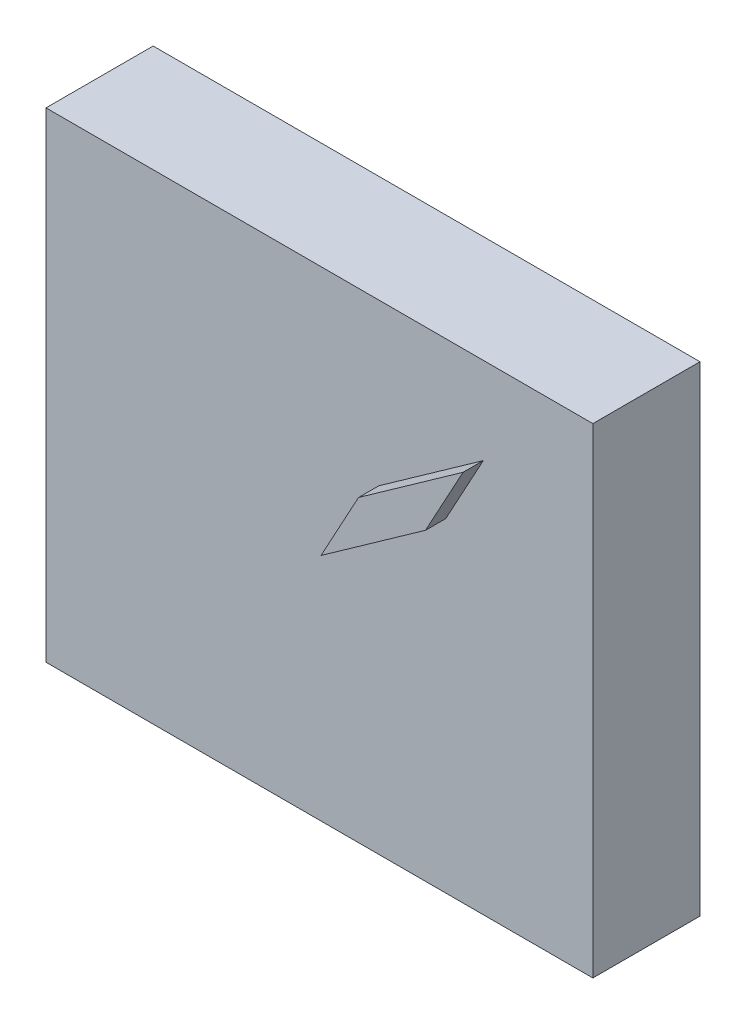
from build123d import *

# Parameters (mm, degrees)
SKETCH_1_W      = 54.1
SKETCH_1_H      = 47.5
EXTRUDE_1_DEPTH = 10.6
EXTRUDE_2_DEPTH = 2


with BuildPart() as part:
    # ｽｹｯﾁ1 → ﾎﾞｽ - 押し出し1 (new body)
    with BuildSketch(Plane.XY):
        with Locations((27.05, 23.75)):
            Rectangle(SKETCH_1_W, SKETCH_1_H)
    extrude(amount=EXTRUDE_1_DEPTH)

    # ｽｹｯﾁ2 → ﾎﾞｽ - 押し出し2 (add)
    with BuildSketch(Plane.XY.offset(10.6)):
        Polygon((43.259439272, 38.907350352), (32.920319496, 31.579624685), (29.20626676, 24.753798037), (39.545386537, 32.081523703), align=None)
    extrude(amount=EXTRUDE_2_DEPTH)


solid = part.part
